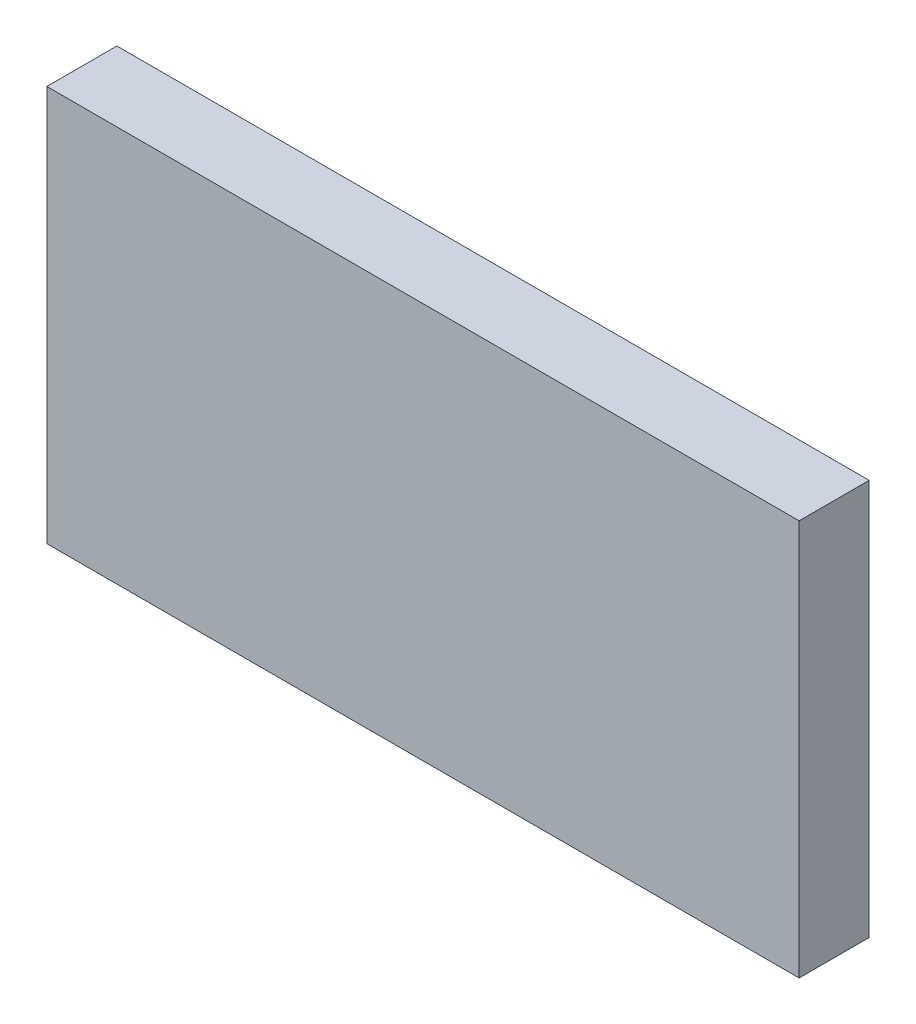
from build123d import *

# Parameters (mm, degrees)
ESBO_O1_W                = 247
ESBO_O1_H                = 130
RESSALTO_EXTRUS_O1_DEPTH = 23


with BuildPart() as part:
    # Esboço1 → Ressalto-extrusão1 (new body)
    with BuildSketch(Plane.XY):
        with Locations((-46.409858807, 16.006257901)):
            Rectangle(ESBO_O1_W, ESBO_O1_H)
    extrude(amount=RESSALTO_EXTRUS_O1_DEPTH)


solid = part.part
